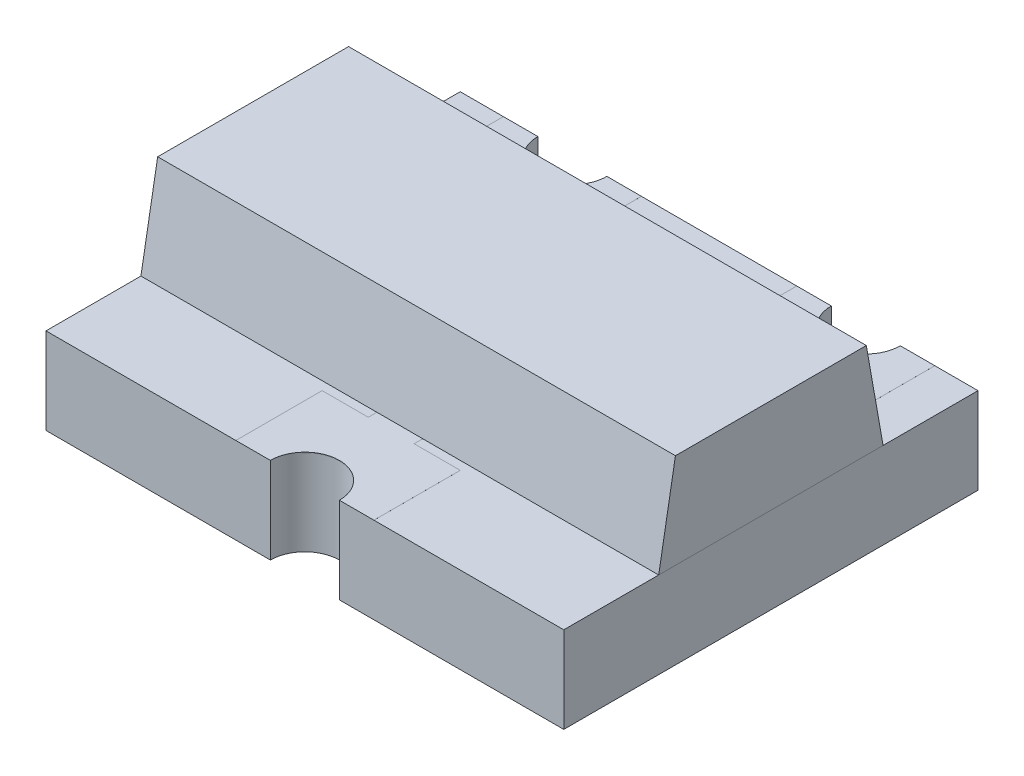
from build123d import *

# Parameters (mm, degrees)
SKETCH1_W             = 2.4
SKETCH1_H             = 0.5
EXTRUDE1_DEPTH        = 1.5
EXTRUDE2_DEPTH        = 1.5
CUT_EXTRUDE1_DEPTH    = 2.05
EXTRUDE3_DEPTH        = 0.0001
EXTRUDE3_DEPTH_BACK   = 0.003
EXTRUDE3_2_DEPTH      = 0.0001
EXTRUDE3_2_DEPTH_BACK = 0.003
EXTRUDE3_3_DEPTH      = 0.0001
EXTRUDE3_3_DEPTH_BACK = 0.003
EXTRUDE4_DEPTH        = 0.0001
EXTRUDE4_DEPTH_BACK   = 0.003
EXTRUDE4_2_DEPTH      = 0.0001
EXTRUDE4_2_DEPTH_BACK = 0.003
EXTRUDE4_3_DEPTH      = 0.0001
EXTRUDE4_3_DEPTH_BACK = 0.003
SKETCH4_W             = 0.026582278
SKETCH4_H             = 0.025316455
SKETCH4_H_2           = 0.025316456
CUT_EXTRUDE2_DEPTH    = 0.01


with BuildPart() as part:
    # Sketch1 → Extrude1 (new body, symmetric)
    with BuildSketch(Plane(origin=(0, 0, 0), x_dir=(0, 0, -1), z_dir=(1, 0, 0))):
        Rectangle(SKETCH1_W, SKETCH1_H)
    extrude(amount=EXTRUDE1_DEPTH, both=True)

    # Sketch2 → Cut-Extrude1 (cut, through all)
    with BuildSketch(Plane.XZ.offset(0.25)):
        with BuildLine():
            Line((0.2, 1.2), (-0.2, 1.2))
            ThreePointArc((-0.2, 1.2), (0, 1), (0.2, 1.2))
        make_face()
        with BuildLine():
            ThreePointArc((-0.65, -1.2), (-0.85, -1), (-1.05, -1.2))
            Line((-1.05, -1.2), (-0.65, -1.2))
        make_face()
        with BuildLine():
            ThreePointArc((1.05, -1.2), (0.85, -1), (0.65, -1.2))
            Line((0.65, -1.2), (1.05, -1.2))
        make_face()
    extrude(amount=-CUT_EXTRUDE1_DEPTH, mode=Mode.SUBTRACT)

    # Sketch4 → Cut-Extrude2 (cut)
    with BuildSketch(Plane.XZ.offset(0.25)):
        Polygon((1.357409322, -0.579474052), (1.432092866, -0.602931331), (1.432092866, -0.62767421), (1.381756632, -0.64409035), (1.432092866, -0.659616457), (1.432092866, -0.685348261), (1.357409322, -0.708587976), (1.357409322, -0.68340997), (1.408892708, -0.670415508), (1.357409322, -0.653999369), (1.357409322, -0.63250016), (1.408892708, -0.616182913), (1.357409322, -0.603366457), align=None)
        Polygon((1.357409322, -0.445296837), (1.432092866, -0.468754116), (1.432092866, -0.493496995), (1.381756632, -0.509913135), (1.432092866, -0.525439242), (1.432092866, -0.551171046), (1.357409322, -0.574410761), (1.357409322, -0.549232755), (1.408892708, -0.536238293), (1.357409322, -0.519822154), (1.357409322, -0.498322945), (1.408892708, -0.482005698), (1.357409322, -0.469189242), align=None)
        Polygon((1.357409322, -0.311119622), (1.432092866, -0.3345769), (1.432092866, -0.35931978), (1.381756632, -0.375735919), (1.432092866, -0.391262027), (1.432092866, -0.416993831), (1.357409322, -0.440233546), (1.357409322, -0.41505554), (1.408892708, -0.402061078), (1.357409322, -0.385644938), (1.357409322, -0.364145729), (1.408892708, -0.347828483), (1.357409322, -0.335012027), align=None)
        with Locations((1.418801727, -0.283271521)):
            Rectangle(SKETCH4_W, SKETCH4_H)
        with BuildLine():
            add(Edge.make_bspline(
                [(1.40092198, -0.166815824), (1.402144102, -0.166852343), (1.404543941, -0.166924054), (1.408051798, -0.167533348), (1.411375482, -0.16852839), (1.41453672, -0.169894506), (1.417501146, -0.171703871), (1.420297161, -0.173885176), (1.422911359, -0.176472683), (1.425319887, -0.179429064), (1.42752455, -0.182710159), (1.429415656, -0.18631264), (1.431042191, -0.190181635), (1.432373366, -0.194336031), (1.433364281, -0.198781501), (1.434087556, -0.203499309), (1.434561076, -0.208492649), (1.434603015, -0.211916238), (1.434624512, -0.213671046)],
                knots=[0, 0, 0, 0, 0.907462679, 1.781953809, 2.635804048, 3.480274448, 4.332887508, 5.208817748, 6.109340518, 7.059474472, 8.037577805, 9.041105121, 10.077237313, 11.152245627, 12.27748741, 13.457227022, 14.696666784, 16, 16, 16, 16], degree=3))
            add(Edge.make_bspline(
                [(1.434624512, -0.213671046), (1.434597247, -0.21568903), (1.434544443, -0.219597217), (1.43415907, -0.225264785), (1.433471121, -0.230528251), (1.43251454, -0.235425998), (1.431311255, -0.240030299), (1.430020611, -0.244463643), (1.428556031, -0.248744936), (1.427455894, -0.251518028), (1.426910904, -0.252891774)],
                knots=[0, 0, 0, 0, 1.203182053, 2.33017619, 3.384818652, 4.366208123, 5.30340534, 6.221361684, 7.118890722, 8, 8, 8, 8], degree=3))
            Line((1.426910904, -0.252891774), (1.402978942, -0.252891774))
            Line((1.402978942, -0.252891774), (1.402978942, -0.250043673))
            add(Edge.make_bspline(
                [(1.402978942, -0.250043673), (1.404059905, -0.248678109), (1.406215484, -0.245955), (1.408983838, -0.241528042), (1.411356849, -0.23686903), (1.413339471, -0.232030636), (1.414915085, -0.227129267), (1.416041991, -0.2222602), (1.416781355, -0.217491217), (1.416862917, -0.214332895), (1.416902993, -0.212781014)],
                knots=[0, 0, 0, 0, 1.030738938, 2.055426519, 3.085610749, 4.123842265, 5.148648843, 6.130724483, 7.081507926, 8, 8, 8, 8], degree=3))
            add(Edge.make_bspline(
                [(1.416902993, -0.212781014), (1.416901657, -0.212352271), (1.416898796, -0.211434366), (1.416778683, -0.209971709), (1.416648283, -0.208322187), (1.416454285, -0.206547796), (1.416219913, -0.204754627), (1.415878731, -0.203086728), (1.415506623, -0.201579962), (1.415139525, -0.200673259), (1.414964702, -0.200241457)],
                knots=[0, 0, 0, 0, 0.806557331, 1.726776592, 2.760222249, 3.920734434, 5.085813889, 6.161303184, 7.124353598, 8, 8, 8, 8], degree=3))
            add(Edge.make_bspline(
                [(1.414964702, -0.200241457), (1.414736149, -0.1997622), (1.414286993, -0.198820358), (1.41348033, -0.197519041), (1.412573518, -0.196363719), (1.41161213, -0.195306974), (1.410461484, -0.194420649), (1.40905428, -0.193803788), (1.407406295, -0.193457421), (1.406230936, -0.193418619), (1.40560948, -0.193398103)],
                knots=[0, 0, 0, 0, 1.025060442, 2.01446193, 2.949256246, 3.85908539, 4.768290539, 5.73153362, 6.800575992, 8, 8, 8, 8], degree=3))
            add(Edge.make_bspline(
                [(1.40560948, -0.193398103), (1.405063873, -0.193429967), (1.403991047, -0.193492622), (1.402455498, -0.194069528), (1.401048086, -0.194980127), (1.399774675, -0.196254099), (1.398656404, -0.19786689), (1.397633759, -0.199784472), (1.396804846, -0.202055523), (1.396366253, -0.203692335), (1.396135588, -0.204553166)],
                knots=[0, 0, 0, 0, 0.825786558, 1.623739628, 2.456775365, 3.355767579, 4.339087636, 5.42728423, 6.646958453, 8, 8, 8, 8], degree=3))
            add(Edge.make_bspline(
                [(1.396135588, -0.204553166), (1.395689878, -0.206522304), (1.394775139, -0.210563612), (1.393596045, -0.216705147), (1.392361392, -0.222841983), (1.391149974, -0.226792288), (1.390558056, -0.22872247)],
                knots=[0, 0, 0, 0, 0.976116373, 2.003306214, 3.02438349, 4, 4, 4, 4], degree=3))
            add(Edge.make_bspline(
                [(1.390558056, -0.22872247), (1.390204336, -0.229760625), (1.389515786, -0.231781492), (1.388363103, -0.234680651), (1.387058091, -0.237324013), (1.385735631, -0.239781157), (1.38425703, -0.241975186), (1.382716285, -0.243968899), (1.381077327, -0.245741204), (1.379319943, -0.247266714), (1.377484875, -0.248611161), (1.375536659, -0.249762187), (1.373475343, -0.250730304), (1.371310886, -0.251522736), (1.369041626, -0.252141567), (1.366664356, -0.252561712), (1.364181105, -0.252860408), (1.362486737, -0.252881176), (1.361622138, -0.252891774)],
                knots=[0, 0, 0, 0, 1.287139616, 2.505537848, 3.65787682, 4.745319116, 5.777517297, 6.75878323, 7.700384896, 8.605120322, 9.485712598, 10.366814604, 11.256335458, 12.154696155, 13.068779358, 14.012730507, 14.985940713, 16, 16, 16, 16], degree=3))
            add(Edge.make_bspline(
                [(1.361622138, -0.252891774), (1.360465992, -0.252854473), (1.358190717, -0.252781067), (1.354861695, -0.252179617), (1.351712876, -0.251153106), (1.34870972, -0.249766747), (1.345895457, -0.247939254), (1.34321797, -0.245747131), (1.340725474, -0.243136821), (1.338426838, -0.240151494), (1.336348032, -0.236864646), (1.334511324, -0.233330641), (1.333004877, -0.22955179), (1.331723646, -0.225571905), (1.330771251, -0.221352512), (1.330051673, -0.216915542), (1.329638672, -0.212241679), (1.329587397, -0.209050268), (1.329561221, -0.207421046)],
                knots=[0, 0, 0, 0, 0.894901293, 1.761149761, 2.608783409, 3.453876344, 4.314933854, 5.200038827, 6.12799933, 7.103249695, 8.113098521, 9.136064399, 10.182719798, 11.259667356, 12.370545059, 13.528828137, 14.738461593, 16, 16, 16, 16], degree=3))
            add(Edge.make_bspline(
                [(1.329561221, -0.207421046), (1.329583575, -0.205752388), (1.329628246, -0.2024179), (1.330003788, -0.197436028), (1.330567386, -0.192484697), (1.331374369, -0.187614536), (1.332383832, -0.182930403), (1.33347328, -0.178507926), (1.334713205, -0.17442886), (1.335667308, -0.171855147), (1.336127676, -0.170613293)],
                knots=[0, 0, 0, 0, 1.065384654, 2.128962885, 3.18847586, 4.246683315, 5.279600907, 6.247539799, 7.154412252, 8, 8, 8, 8], degree=3))
            Line((1.336127676, -0.170613293), (1.358675145, -0.170613293))
            Line((1.358675145, -0.170613293), (1.358675145, -0.173441616))
            add(Edge.make_bspline(
                [(1.358675145, -0.173441616), (1.357876, -0.174515174), (1.356245126, -0.176706063), (1.354141092, -0.180354786), (1.352209389, -0.184328245), (1.35048006, -0.188595928), (1.349060928, -0.193069219), (1.348031492, -0.197646565), (1.347392471, -0.202273682), (1.347319325, -0.205375266), (1.34728274, -0.206926584)],
                knots=[0, 0, 0, 0, 0.892231706, 1.82084296, 2.804411717, 3.838445872, 4.890103822, 5.931567007, 6.965432763, 8, 8, 8, 8], degree=3))
            add(Edge.make_bspline(
                [(1.34728274, -0.206926584), (1.347307388, -0.208021822), (1.347356814, -0.210218), (1.347700294, -0.2134934), (1.348379997, -0.216726573), (1.349191103, -0.218763645), (1.349596822, -0.219782597)],
                knots=[0, 0, 0, 0, 0.99896713, 2.003134239, 3.001159596, 4, 4, 4, 4], degree=3))
            add(Edge.make_bspline(
                [(1.349596822, -0.219782597), (1.349798017, -0.220216302), (1.350200272, -0.221083424), (1.350979663, -0.222291326), (1.351896903, -0.223410919), (1.352950168, -0.224415465), (1.354131235, -0.225239604), (1.355393906, -0.225880883), (1.356756839, -0.226240311), (1.357690879, -0.226286335), (1.358160904, -0.226309495)],
                knots=[0, 0, 0, 0, 1.005120364, 2.009570296, 3.014977851, 4.045438181, 5.061509448, 6.035608779, 7.011484765, 8, 8, 8, 8], degree=3))
            add(Edge.make_bspline(
                [(1.358160904, -0.226309495), (1.358798835, -0.226274701), (1.360017863, -0.226208212), (1.361731559, -0.225608215), (1.363194671, -0.224610546), (1.364187665, -0.223457447), (1.364886424, -0.222340468), (1.365391664, -0.22129995), (1.365905087, -0.220100499), (1.366394284, -0.218723051), (1.36688833, -0.217187916), (1.367363, -0.215478993), (1.36781256, -0.213596386), (1.368098712, -0.212280495), (1.36824793, -0.211594305)],
                knots=[0, 0, 0, 0, 1.174343879, 2.244064321, 3.303704314, 4.407076671, 5.02483983, 5.732197225, 6.53898402, 7.431906431, 8.428480183, 9.514816237, 10.704066255, 12, 12, 12, 12], degree=3))
            add(Edge.make_bspline(
                [(1.36824793, -0.211594305), (1.36862403, -0.209761546), (1.369361688, -0.206166901), (1.370464919, -0.200763811), (1.371767782, -0.19526851), (1.372900174, -0.19159214), (1.373489227, -0.189679748)],
                knots=[0, 0, 0, 0, 0.995794372, 1.953081347, 2.935223864, 4, 4, 4, 4], degree=3))
            add(Edge.make_bspline(
                [(1.373489227, -0.189679748), (1.373808583, -0.188733258), (1.374433296, -0.186881769), (1.375518016, -0.184240255), (1.37669998, -0.181791087), (1.377922905, -0.179513216), (1.379284597, -0.177449747), (1.380701928, -0.175564911), (1.382207902, -0.173867749), (1.383823255, -0.172378618), (1.385533932, -0.171050616), (1.387383584, -0.169935611), (1.389332747, -0.168948996), (1.391413181, -0.168157378), (1.393624143, -0.1675729), (1.395951027, -0.167140221), (1.398396179, -0.166849012), (1.400070649, -0.166827011), (1.40092198, -0.166815824)],
                knots=[0, 0, 0, 0, 1.237247399, 2.420255609, 3.534416354, 4.605351393, 5.620193117, 6.593738998, 7.524982051, 8.426564095, 9.311945829, 10.20281032, 11.097671666, 12.01534975, 12.954438892, 13.926750701, 14.945921247, 16, 16, 16, 16], degree=3))
        make_face()
        with BuildLine():
            Line((1.432092866, -0.074410761), (1.432092866, -0.098461394))
            Line((1.432092866, -0.098461394), (1.424260588, -0.098461394))
            add(Edge.make_bspline(
                [(1.424260588, -0.098461394), (1.425069491, -0.099554535), (1.426629045, -0.101662095), (1.428704658, -0.104837359), (1.430496984, -0.107858328), (1.432003008, -0.110796755), (1.433230662, -0.113796159), (1.434042817, -0.117030317), (1.434546898, -0.120531344), (1.434598066, -0.122958496), (1.434624512, -0.124212976)],
                knots=[0, 0, 0, 0, 1.15097647, 2.219065785, 3.209751872, 4.123278731, 5.012494873, 5.946522673, 6.938654008, 8, 8, 8, 8], degree=3))
            add(Edge.make_bspline(
                [(1.434624512, -0.124212976), (1.434601554, -0.125229245), (1.434556848, -0.127208213), (1.434215267, -0.130086602), (1.433666366, -0.132788253), (1.432899684, -0.135318195), (1.431888271, -0.13766922), (1.430637573, -0.139826899), (1.429175705, -0.141813567), (1.427499451, -0.143617219), (1.425578304, -0.145207764), (1.423455604, -0.146594835), (1.421120951, -0.147770642), (1.418569589, -0.148712281), (1.415811143, -0.149467214), (1.412831937, -0.149991192), (1.409644797, -0.150311771), (1.407449669, -0.150343712), (1.406321505, -0.150360128)],
                knots=[0, 0, 0, 0, 1.108887696, 2.159324556, 3.158383213, 4.114277414, 5.039206009, 5.945047284, 6.830075132, 7.726032535, 8.625162295, 9.545152215, 10.487958828, 11.471559655, 12.508379831, 13.604991163, 14.769110247, 16, 16, 16, 16], degree=3))
            Line((1.406321505, -0.150360128), (1.357409322, -0.150360128))
            Line((1.357409322, -0.150360128), (1.357409322, -0.126309495))
            Line((1.357409322, -0.126309495), (1.394988436, -0.126309495))
            add(Edge.make_bspline(
                [(1.394988436, -0.126309495), (1.395904907, -0.12630786), (1.397659122, -0.126304729), (1.400164929, -0.12622239), (1.402433102, -0.12610149), (1.40447513, -0.125962785), (1.406321881, -0.125709768), (1.407988042, -0.12533206), (1.409507644, -0.124861234), (1.410414345, -0.124396915), (1.410850778, -0.124173419)],
                knots=[0, 0, 0, 0, 1.361401701, 2.605856924, 3.723918663, 4.735739235, 5.645738665, 6.489217889, 7.27279937, 8, 8, 8, 8], degree=3))
            add(Edge.make_bspline(
                [(1.410850778, -0.124173419), (1.411249416, -0.123943378), (1.412033105, -0.123491136), (1.413040386, -0.12257135), (1.413876778, -0.121495268), (1.414551477, -0.120226026), (1.415026638, -0.118729905), (1.415413818, -0.117004998), (1.415584035, -0.115012606), (1.415618777, -0.113605236), (1.41563717, -0.112860128)],
                knots=[0, 0, 0, 0, 0.848923305, 1.668910138, 2.502822694, 3.358979167, 4.311113223, 5.396624103, 6.621686681, 8, 8, 8, 8], degree=3))
            add(Edge.make_bspline(
                [(1.41563717, -0.112860128), (1.415617222, -0.112319208), (1.415576235, -0.111207836), (1.415387204, -0.109496447), (1.414983045, -0.107714807), (1.414339075, -0.105196454), (1.413152112, -0.102021762), (1.411794586, -0.099657385), (1.411107898, -0.098461394)],
                knots=[0, 0, 0, 0, 0.638098464, 1.31103257, 2.025970928, 2.789492669, 4.376004971, 6, 6, 6, 6], degree=3))
            Line((1.411107898, -0.098461394), (1.357409322, -0.098461394))
            Line((1.357409322, -0.098461394), (1.357409322, -0.074410761))
            Line((1.357409322, -0.074410761), (1.432092866, -0.074410761))
        make_face()
        with BuildLine():
            Line((1.432092866, 0.023057593), (1.432092866, -0.00099304))
            Line((1.432092866, -0.00099304), (1.394513752, -0.00099304))
            add(Edge.make_bspline(
                [(1.394513752, -0.00099304), (1.39298333, -0.00101385), (1.389924446, -0.001055445), (1.386167044, -0.001383651), (1.383319969, -0.001723123), (1.381490218, -0.00209788), (1.3799419, -0.002528222), (1.379056161, -0.002940651), (1.378651411, -0.003129116)],
                knots=[0, 0, 0, 0, 1.709225407, 3.416259723, 4.21101956, 4.910102269, 5.501957085, 6, 6, 6, 6], degree=3))
            add(Edge.make_bspline(
                [(1.378651411, -0.003129116), (1.378253279, -0.003373542), (1.377472685, -0.003852775), (1.3764608, -0.004790617), (1.375624056, -0.005887163), (1.374961207, -0.007166296), (1.374466799, -0.008647883), (1.374120517, -0.010367713), (1.373908294, -0.012347247), (1.373879994, -0.013756174), (1.373865018, -0.014501742)],
                knots=[0, 0, 0, 0, 0.860284341, 1.686708632, 2.528476982, 3.393563585, 4.332150703, 5.400907339, 6.624626855, 8, 8, 8, 8], degree=3))
            add(Edge.make_bspline(
                [(1.373865018, -0.014501742), (1.373924963, -0.015632699), (1.374047287, -0.017940532), (1.37471602, -0.020814945), (1.375569249, -0.023128581), (1.376335164, -0.024979368), (1.377292463, -0.026894983), (1.378019154, -0.028178538), (1.37839429, -0.028841141)],
                knots=[0, 0, 0, 0, 1.338233385, 2.730803257, 3.468495571, 4.255080394, 5.099229486, 6, 6, 6, 6], degree=3))
            Line((1.37839429, -0.028841141), (1.432092866, -0.028841141))
            Line((1.432092866, -0.028841141), (1.432092866, -0.052891774))
            Line((1.432092866, -0.052891774), (1.357409322, -0.052891774))
            Line((1.357409322, -0.052891774), (1.357409322, -0.028841141))
            Line((1.357409322, -0.028841141), (1.3652416, -0.028841141))
            add(Edge.make_bspline(
                [(1.3652416, -0.028841141), (1.364435163, -0.027783903), (1.362865384, -0.025725928), (1.360831974, -0.022549175), (1.359022117, -0.019478464), (1.357509983, -0.016423942), (1.356311383, -0.013299444), (1.35549578, -0.010031813), (1.354952832, -0.006615101), (1.35490302, -0.004278428), (1.354877676, -0.003089559)],
                knots=[0, 0, 0, 0, 1.126064518, 2.191951536, 3.19307265, 4.144813015, 5.076393104, 6.021983703, 6.993610568, 8, 8, 8, 8], degree=3))
            add(Edge.make_bspline(
                [(1.354877676, -0.003089559), (1.354903077, -0.002093294), (1.354952663, -0.000148407), (1.355262215, 0.002686442), (1.355813438, 0.005357549), (1.356609294, 0.007850934), (1.357600654, 0.010186617), (1.358804629, 0.012360301), (1.360267926, 0.014346105), (1.361927805, 0.016174425), (1.363819332, 0.017812888), (1.365947823, 0.019212251), (1.368290311, 0.020408123), (1.370839855, 0.021395442), (1.373618813, 0.022146481), (1.376612194, 0.022662664), (1.379823091, 0.023016942), (1.382039097, 0.023043772), (1.383180683, 0.023057593)],
                knots=[0, 0, 0, 0, 1.088244909, 2.124447647, 3.110254678, 4.062235362, 4.978491991, 5.877983887, 6.769571508, 7.666696544, 8.570415953, 9.495151274, 10.442024977, 11.43832337, 12.476026402, 13.580659577, 14.753665747, 16, 16, 16, 16], degree=3))
            Line((1.383180683, 0.023057593), (1.432092866, 0.023057593))
        make_face()
        Polygon((1.432092866, 0.117994302), (1.432092866, 0.045842403), (1.332092866, 0.045842403), (1.332092866, 0.071158859), (1.413105524, 0.071158859), (1.413105524, 0.117994302), align=None)
        Polygon((1.432092866, 0.205336074), (1.432092866, 0.133184176), (1.332092866, 0.133184176), (1.332092866, 0.205336074), (1.351080208, 0.205336074), (1.351080208, 0.158500631), (1.368801727, 0.158500631), (1.368801727, 0.201538606), (1.387789069, 0.201538606), (1.387789069, 0.158500631), (1.413105524, 0.158500631), (1.413105524, 0.205336074), align=None)
        with BuildLine():
            add(Edge.make_bspline(
                [(1.382191759, 0.321791771), (1.383339447, 0.321772455), (1.385612334, 0.321734203), (1.38897714, 0.321439012), (1.392242816, 0.320912986), (1.395427064, 0.320233805), (1.398505992, 0.319311299), (1.401513569, 0.318229586), (1.404419063, 0.31691994), (1.407220497, 0.315415087), (1.4098926, 0.313765615), (1.412412809, 0.311990866), (1.414796026, 0.310145087), (1.41699092, 0.308155774), (1.41903294, 0.306076592), (1.420923754, 0.303901064), (1.422627185, 0.301595999), (1.423650069, 0.299988837), (1.424161695, 0.299184967)],
                knots=[0, 0, 0, 0, 1.105570398, 2.18947457, 3.250358341, 4.290584537, 5.323553275, 6.344225964, 7.367641686, 8.3905646, 9.405808457, 10.390761353, 11.358902336, 12.307789878, 13.241960776, 14.165076779, 15.082208636, 16, 16, 16, 16], degree=3))
            add(Edge.make_bspline(
                [(1.424161695, 0.299184967), (1.424874046, 0.297945787), (1.426302382, 0.295461104), (1.427967773, 0.291476539), (1.429385809, 0.287349271), (1.43039302, 0.282981956), (1.431164499, 0.278343867), (1.431714982, 0.273345824), (1.432019079, 0.267945377), (1.43206771, 0.264210397), (1.432092866, 0.262278321)],
                knots=[0, 0, 0, 0, 0.896331627, 1.797236794, 2.705411718, 3.632841792, 4.606367508, 5.655603524, 6.787262262, 8, 8, 8, 8], degree=3))
            Line((1.432092866, 0.262278321), (1.432092866, 0.226855062))
            Line((1.432092866, 0.226855062), (1.332092866, 0.226855062))
            Line((1.332092866, 0.226855062), (1.332092866, 0.263287024))
            add(Edge.make_bspline(
                [(1.332092866, 0.263287024), (1.332109761, 0.265265712), (1.332142348, 0.269082356), (1.332555657, 0.274593251), (1.333164078, 0.279688767), (1.334060087, 0.284377578), (1.335167973, 0.288688435), (1.336560442, 0.292611262), (1.338052626, 0.29622761), (1.339327234, 0.298406131), (1.339944923, 0.299461865)],
                knots=[0, 0, 0, 0, 1.267100211, 2.444079055, 3.537724964, 4.552266402, 5.499704501, 6.385138932, 7.217420793, 8, 8, 8, 8], degree=3))
            add(Edge.make_bspline(
                [(1.339944923, 0.299461865), (1.340481464, 0.300312819), (1.341548377, 0.302004943), (1.34333023, 0.304406158), (1.345286307, 0.306635585), (1.347338125, 0.308764089), (1.349541013, 0.310743903), (1.351879717, 0.312587116), (1.354357824, 0.314290882), (1.356967243, 0.315849038), (1.359697483, 0.317269123), (1.362569828, 0.318461203), (1.365552702, 0.319500565), (1.368651641, 0.320346647), (1.371869031, 0.321002977), (1.375206511, 0.321449061), (1.378659699, 0.321732494), (1.381004493, 0.321771845), (1.382191759, 0.321791771)],
                knots=[0, 0, 0, 0, 0.964043478, 1.917004671, 2.862223898, 3.805158963, 4.749279098, 5.698713747, 6.657523689, 7.629652222, 8.610369353, 9.604453025, 10.607693792, 11.636365947, 12.681120053, 13.752669011, 14.862083412, 16, 16, 16, 16], degree=3))
        make_face()
        with BuildLine():
            add(Edge.make_bspline(
                [(1.382033531, 0.295209492), (1.380455675, 0.29516309), (1.377410007, 0.295073522), (1.373005805, 0.294409979), (1.36897254, 0.293230448), (1.365856036, 0.291901212), (1.363583021, 0.290562667), (1.36198469, 0.289435373), (1.360470507, 0.288185646), (1.359061662, 0.286795053), (1.357754627, 0.285259865), (1.356525717, 0.283598607), (1.355397071, 0.281798565), (1.354737065, 0.280525534), (1.354402993, 0.279881169)],
                knots=[0, 0, 0, 0, 1.694561208, 3.270940604, 4.767926833, 6.198032689, 6.896357436, 7.597727349, 8.296769799, 9.00280713, 9.720956486, 10.460265288, 11.220639329, 12, 12, 12, 12], degree=3))
            add(Edge.make_bspline(
                [(1.354402993, 0.279881169), (1.354096478, 0.279206234), (1.353488946, 0.277868466), (1.352754859, 0.27579819), (1.352192532, 0.273705489), (1.351720109, 0.271511262), (1.351442973, 0.269034502), (1.351230297, 0.26611201), (1.351093369, 0.262655337), (1.351084799, 0.260168742), (1.351080208, 0.258836865)],
                knots=[0, 0, 0, 0, 0.826913061, 1.638999358, 2.447478739, 3.243919028, 4.140906711, 5.225381046, 6.513851968, 8, 8, 8, 8], degree=3))
            Line((1.351080208, 0.258836865), (1.351080208, 0.252171517))
            Line((1.351080208, 0.252171517), (1.413105524, 0.252171517))
            Line((1.413105524, 0.252171517), (1.413105524, 0.258836865))
            add(Edge.make_bspline(
                [(1.413105524, 0.258836865), (1.413100482, 0.259595057), (1.413090749, 0.261058793), (1.413051596, 0.263175241), (1.412991447, 0.265140022), (1.412919049, 0.266947308), (1.412806399, 0.268597111), (1.412632409, 0.270084304), (1.412495711, 0.271421114), (1.412218588, 0.272993632), (1.41181234, 0.274848802), (1.411129269, 0.277015597), (1.410279671, 0.279156294), (1.409594596, 0.280544845), (1.409248721, 0.281245884)],
                knots=[0, 0, 0, 0, 1.186788252, 2.291168447, 3.31326867, 4.263560303, 5.122314491, 5.900668105, 6.60723418, 7.224768558, 8.398927205, 9.577205322, 10.776800932, 12, 12, 12, 12], degree=3))
            add(Edge.make_bspline(
                [(1.409248721, 0.281245884), (1.408905243, 0.281829596), (1.408229756, 0.282977528), (1.407123916, 0.284621707), (1.405888832, 0.286108319), (1.404606041, 0.287514846), (1.403214462, 0.288766006), (1.401770921, 0.289943305), (1.400196379, 0.290928546), (1.398007444, 0.292177416), (1.394980287, 0.293420992), (1.391008363, 0.294454607), (1.386649209, 0.295093399), (1.383611503, 0.295169803), (1.382033531, 0.295209492)],
                knots=[0, 0, 0, 0, 0.755184287, 1.485151634, 2.206180267, 2.908413556, 3.605665444, 4.291074465, 4.982332562, 5.673512475, 7.100235687, 8.614142391, 10.24117603, 12, 12, 12, 12], degree=3))
        make_face(mode=Mode.SUBTRACT)
        with Locations((1.418801727, 0.35343734)):
            Rectangle(SKETCH4_W, SKETCH4_H_2)
        with BuildLine():
            add(Edge.make_bspline(
                [(1.434624512, 0.428081327), (1.434602693, 0.426491218), (1.434559867, 0.423370089), (1.434083055, 0.418798697), (1.433364984, 0.414433703), (1.432345407, 0.410286763), (1.430996034, 0.406383478), (1.429360961, 0.402711095), (1.427361123, 0.399311887), (1.425778506, 0.397244904), (1.424992392, 0.396218195)],
                knots=[0, 0, 0, 0, 1.123640227, 2.2055255, 3.245221982, 4.248949655, 5.220213072, 6.160941522, 7.086505793, 8, 8, 8, 8], degree=3))
            add(Edge.make_bspline(
                [(1.424992392, 0.396218195), (1.424137559, 0.39526656), (1.422431198, 0.39336697), (1.419460655, 0.390899343), (1.416171682, 0.388781267), (1.412580029, 0.386969012), (1.408660143, 0.38553706), (1.404410249, 0.384544525), (1.399852919, 0.383916921), (1.396704715, 0.38385097), (1.395087328, 0.383817087)],
                knots=[0, 0, 0, 0, 0.916342154, 1.829140869, 2.758848968, 3.716597128, 4.708179637, 5.743612459, 6.840783343, 8, 8, 8, 8], degree=3))
            add(Edge.make_bspline(
                [(1.395087328, 0.383817087), (1.393384101, 0.383855847), (1.390083021, 0.38393097), (1.385310834, 0.38459473), (1.380893153, 0.385664342), (1.376841245, 0.3872019), (1.373148053, 0.389132342), (1.369776218, 0.391396835), (1.366733294, 0.394017361), (1.364987855, 0.396024499), (1.364114227, 0.397029112)],
                knots=[0, 0, 0, 0, 1.171797512, 2.271099083, 3.308930235, 4.294129479, 5.24602549, 6.17106565, 7.084581485, 8, 8, 8, 8], degree=3))
            add(Edge.make_bspline(
                [(1.364114227, 0.397029112), (1.363345573, 0.39805494), (1.361798981, 0.400118984), (1.359902261, 0.403517865), (1.358304295, 0.407134537), (1.357029335, 0.41095782), (1.35608009, 0.414940522), (1.355384324, 0.419009962), (1.354956181, 0.423153879), (1.354903971, 0.425944244), (1.354877676, 0.427349524)],
                knots=[0, 0, 0, 0, 0.952013349, 1.915525331, 2.885385798, 3.888123097, 4.906830296, 5.926067872, 6.955529031, 8, 8, 8, 8], degree=3))
            add(Edge.make_bspline(
                [(1.354877676, 0.427349524), (1.354894035, 0.428596336), (1.354926201, 0.431047992), (1.355257359, 0.434646718), (1.355756376, 0.438098715), (1.356499947, 0.441398006), (1.357422761, 0.444564203), (1.358446909, 0.447627653), (1.359586819, 0.45059189), (1.360470776, 0.452492644), (1.360910113, 0.45343734)],
                knots=[0, 0, 0, 0, 1.107572103, 2.177862056, 3.208491727, 4.204802822, 5.180069889, 6.137814326, 7.074472616, 8, 8, 8, 8], degree=3))
            Line((1.360910113, 0.45343734), (1.381459955, 0.45343734))
            Line((1.381459955, 0.45343734), (1.381459955, 0.450094777))
            add(Edge.make_bspline(
                [(1.381459955, 0.450094777), (1.381043063, 0.449594981), (1.380136126, 0.448507689), (1.378709241, 0.446725865), (1.377187976, 0.444570953), (1.376299309, 0.442926284), (1.375823088, 0.442044935)],
                knots=[0, 0, 0, 0, 0.792806788, 1.724728901, 2.780722718, 4, 4, 4, 4], degree=3))
            add(Edge.make_bspline(
                [(1.375823088, 0.442044935), (1.375383543, 0.441116276), (1.374479051, 0.43920529), (1.373614767, 0.436658171), (1.373078785, 0.434457847), (1.372816761, 0.432649897), (1.372629146, 0.430715787), (1.372609362, 0.429380614), (1.372599195, 0.42869446)],
                knots=[0, 0, 0, 0, 1.332411269, 2.741822805, 3.48048496, 4.268099981, 5.109965479, 6, 6, 6, 6], degree=3))
            add(Edge.make_bspline(
                [(1.372599195, 0.42869446), (1.372618536, 0.427928828), (1.372656017, 0.426445069), (1.37293593, 0.424284607), (1.373404503, 0.422260327), (1.374080746, 0.420371096), (1.374941051, 0.418616536), (1.375961211, 0.416980866), (1.377213201, 0.415505224), (1.378631633, 0.414163598), (1.380221957, 0.412976026), (1.381948496, 0.411949297), (1.383806375, 0.411066564), (1.385804287, 0.410364673), (1.387934148, 0.409807162), (1.390196958, 0.409417597), (1.392596556, 0.409175818), (1.394242852, 0.409147876), (1.395087328, 0.409133543)],
                knots=[0, 0, 0, 0, 1.087164589, 2.106874378, 3.088024391, 4.032801718, 4.949890679, 5.859058447, 6.763003849, 7.690312844, 8.626654282, 9.575690722, 10.539030902, 11.54301425, 12.578634972, 13.662366762, 14.800897888, 16, 16, 16, 16], degree=3))
            add(Edge.make_bspline(
                [(1.395087328, 0.409133543), (1.395951485, 0.409148317), (1.397630497, 0.409177023), (1.400072108, 0.409410537), (1.402353539, 0.409826428), (1.404478859, 0.410397676), (1.406444878, 0.411122024), (1.408242274, 0.412027142), (1.409899081, 0.413063498), (1.411361693, 0.414308056), (1.412678015, 0.41567194), (1.413814149, 0.417186831), (1.414762294, 0.418846071), (1.415566757, 0.420628251), (1.416145156, 0.422561292), (1.416581847, 0.424617828), (1.416870404, 0.426807384), (1.416891967, 0.428317737), (1.416902993, 0.42909003)],
                knots=[0, 0, 0, 0, 1.230336593, 2.390482092, 3.487897344, 4.52859895, 5.520747884, 6.465347575, 7.38981449, 8.296085817, 9.192433006, 10.084246191, 10.984321635, 11.908883871, 12.862027947, 13.850751296, 14.901019963, 16, 16, 16, 16], degree=3))
            add(Edge.make_bspline(
                [(1.416902993, 0.42909003), (1.416894138, 0.42981578), (1.416876876, 0.431230603), (1.416669433, 0.433291325), (1.416359044, 0.435241751), (1.415917412, 0.437074021), (1.415412213, 0.438785608), (1.414835016, 0.44034724), (1.414232371, 0.441760362), (1.413764557, 0.442621635), (1.413540651, 0.443033859)],
                knots=[0, 0, 0, 0, 1.201100869, 2.341500598, 3.425337164, 4.468451875, 5.459559168, 6.378110228, 7.223726512, 8, 8, 8, 8], degree=3))
            add(Edge.make_bspline(
                [(1.413540651, 0.443033859), (1.413112965, 0.443742215), (1.412291006, 0.445103589), (1.410870546, 0.446928707), (1.409464106, 0.448572832), (1.408507338, 0.449596938), (1.408042233, 0.450094777)],
                knots=[0, 0, 0, 0, 1.105932972, 2.12546697, 3.088749538, 4, 4, 4, 4], degree=3))
            Line((1.408042233, 0.450094777), (1.408042233, 0.45343734))
            Line((1.408042233, 0.45343734), (1.428750303, 0.45343734))
            add(Edge.make_bspline(
                [(1.428750303, 0.45343734), (1.429187845, 0.452491963), (1.430063035, 0.450600983), (1.431216185, 0.447686205), (1.432189065, 0.444692963), (1.433081411, 0.441641733), (1.433779606, 0.438472101), (1.434268836, 0.435154752), (1.434570575, 0.431673447), (1.434606288, 0.429295031), (1.434624512, 0.428081327)],
                knots=[0, 0, 0, 0, 0.952024047, 1.90427691, 2.862762905, 3.827874523, 4.80891974, 5.826446878, 6.890837857, 8, 8, 8, 8], degree=3))
        make_face()
        with BuildLine():
            add(Edge.make_bspline(
                [(1.394790651, 0.545842403), (1.396295483, 0.545817484), (1.399228804, 0.545768908), (1.403501624, 0.5452327), (1.407532065, 0.544409237), (1.411332903, 0.543275913), (1.414875949, 0.541758059), (1.418171903, 0.539915645), (1.421224085, 0.537742054), (1.424014312, 0.535251736), (1.426512504, 0.53245025), (1.428708697, 0.529376485), (1.430515745, 0.526006618), (1.432042294, 0.522397872), (1.433198396, 0.518508565), (1.434016346, 0.514349471), (1.434550678, 0.509931961), (1.43459949, 0.506893596), (1.434624512, 0.505336074)],
                knots=[0, 0, 0, 0, 1.120122129, 2.18341868, 3.201215738, 4.181270334, 5.131540819, 6.065757527, 6.988093576, 7.916512302, 8.844931028, 9.778115023, 10.722851943, 11.686686084, 12.691660064, 13.738321946, 14.84062285, 16, 16, 16, 16], degree=3))
            add(Edge.make_bspline(
                [(1.434624512, 0.505336074), (1.434599572, 0.503778526), (1.43455092, 0.500740108), (1.43401545, 0.496322973), (1.433202733, 0.492168754), (1.432033497, 0.488284102), (1.430521407, 0.484669791), (1.428707965, 0.481295964), (1.426512712, 0.478221782), (1.424014202, 0.47542058), (1.421224317, 0.472929543), (1.418171087, 0.470758538), (1.414881295, 0.468907599), (1.41132402, 0.467427207), (1.407536812, 0.466254675), (1.403500814, 0.465441896), (1.399229023, 0.464902579), (1.396295557, 0.464854441), (1.394790651, 0.464829745)],
                knots=[0, 0, 0, 0, 1.159424321, 2.261770074, 3.308474541, 4.308788811, 5.277191138, 6.221966496, 7.15518846, 8.08364496, 9.01210146, 9.934475036, 10.868729753, 11.817121636, 12.798654016, 13.816492484, 14.879832297, 16, 16, 16, 16], degree=3))
            add(Edge.make_bspline(
                [(1.394790651, 0.464829745), (1.393279218, 0.464854847), (1.39032619, 0.46490389), (1.386027443, 0.465439557), (1.381966347, 0.46625652), (1.378153796, 0.467422051), (1.37459132, 0.468928329), (1.371285131, 0.470775275), (1.368238358, 0.472971029), (1.365448193, 0.475480464), (1.362953665, 0.47829323), (1.36077556, 0.481380728), (1.358966767, 0.484744268), (1.357439002, 0.488344621), (1.356306456, 0.492232282), (1.3554883, 0.496368909), (1.354950391, 0.500766392), (1.354902356, 0.503785117), (1.354877676, 0.505336074)],
                knots=[0, 0, 0, 0, 1.123883205, 2.195836198, 3.217400301, 4.202580581, 5.156396106, 6.089661422, 7.013912723, 7.944661364, 8.875797629, 9.805201257, 10.748976071, 11.711828658, 12.709674189, 13.755270167, 14.846705509, 16, 16, 16, 16], degree=3))
            add(Edge.make_bspline(
                [(1.354877676, 0.505336074), (1.354902388, 0.506906818), (1.354950502, 0.509964994), (1.355486841, 0.514408323), (1.356299367, 0.518582453), (1.357467437, 0.522480062), (1.358970706, 0.52610407), (1.360825653, 0.529451247), (1.363000003, 0.532536205), (1.365529832, 0.535304468), (1.368324786, 0.537788226), (1.371382466, 0.539950583), (1.374690041, 0.541786059), (1.378251917, 0.543261802), (1.382044549, 0.544436004), (1.386078975, 0.545256416), (1.390353882, 0.545762568), (1.393286025, 0.545815329), (1.394790651, 0.545842403)],
                knots=[0, 0, 0, 0, 1.167473013, 2.273023816, 3.322954552, 4.326451713, 5.293391623, 6.234801871, 7.166614545, 8.093305908, 9.017100806, 9.942078766, 10.872536262, 11.824015763, 12.804065898, 13.820367293, 14.881523901, 16, 16, 16, 16], degree=3))
        make_face()
        with BuildLine():
            add(Edge.make_bspline(
                [(1.413283531, 0.516135125), (1.412783267, 0.516489701), (1.41176517, 0.517211304), (1.410065673, 0.518092759), (1.408223886, 0.518843069), (1.406199127, 0.519463906), (1.403908782, 0.519978707), (1.40125783, 0.520277297), (1.39822308, 0.520510848), (1.396070251, 0.520520717), (1.3949291, 0.520525948)],
                knots=[0, 0, 0, 0, 0.765135464, 1.557141201, 2.384449913, 3.246599353, 4.1996426, 5.311961702, 6.575150963, 8, 8, 8, 8], degree=3))
            add(Edge.make_bspline(
                [(1.3949291, 0.520525948), (1.393854226, 0.520508214), (1.391794885, 0.520474238), (1.388835021, 0.520288454), (1.386145523, 0.519936994), (1.383720815, 0.519443477), (1.381548744, 0.518835888), (1.379616416, 0.518101086), (1.377902461, 0.517267648), (1.37689734, 0.516581893), (1.376416442, 0.516253796)],
                knots=[0, 0, 0, 0, 1.337015307, 2.56157572, 3.686511827, 4.707709802, 5.636963675, 6.488272502, 7.276717686, 8, 8, 8, 8], degree=3))
            add(Edge.make_bspline(
                [(1.376416442, 0.516253796), (1.375978797, 0.515915133), (1.375124055, 0.515253708), (1.374017734, 0.514097207), (1.373147927, 0.512809706), (1.372443194, 0.511444764), (1.371967098, 0.509989081), (1.371601512, 0.508488884), (1.371383088, 0.506931286), (1.371350036, 0.505870749), (1.371333373, 0.505336074)],
                knots=[0, 0, 0, 0, 1.058303018, 2.066917725, 3.046948061, 4.023234392, 4.996907708, 5.970172105, 6.976653347, 8, 8, 8, 8], degree=3))
            add(Edge.make_bspline(
                [(1.371333373, 0.505336074), (1.371344402, 0.504808172), (1.371365977, 0.503775612), (1.371544493, 0.502272535), (1.371844492, 0.500856882), (1.372248678, 0.499511717), (1.372860054, 0.498226569), (1.373708872, 0.496995292), (1.374785451, 0.495779905), (1.375635786, 0.495041577), (1.376080208, 0.494655695)],
                knots=[0, 0, 0, 0, 1.04189444, 2.037910168, 2.982338511, 3.896140384, 4.804271323, 5.778885192, 6.839150358, 8, 8, 8, 8], degree=3))
            add(Edge.make_bspline(
                [(1.376080208, 0.494655695), (1.376553875, 0.494320261), (1.377547983, 0.493616271), (1.379268353, 0.492767082), (1.381213844, 0.491997783), (1.38340498, 0.491318494), (1.38587252, 0.490787309), (1.388631133, 0.490429121), (1.391681068, 0.490184441), (1.393814374, 0.490159325), (1.3949291, 0.490146201)],
                knots=[0, 0, 0, 0, 0.70629823, 1.482341141, 2.329662943, 3.254583898, 4.274063958, 5.401087491, 6.641978366, 8, 8, 8, 8], degree=3))
            add(Edge.make_bspline(
                [(1.3949291, 0.490146201), (1.395931835, 0.490152151), (1.39787396, 0.490163675), (1.400676344, 0.49040574), (1.40328461, 0.490693009), (1.405673261, 0.491178096), (1.407862425, 0.491756439), (1.409820565, 0.492489102), (1.4115683, 0.493328455), (1.412591979, 0.494023679), (1.413085746, 0.494359017)],
                knots=[0, 0, 0, 0, 1.270931856, 2.461574991, 3.564842381, 4.596079713, 5.549239655, 6.432768418, 7.244053423, 8, 8, 8, 8], degree=3))
            add(Edge.make_bspline(
                [(1.413085746, 0.494359017), (1.41350265, 0.494699309), (1.414324604, 0.495370215), (1.415398888, 0.496519025), (1.416278507, 0.497780767), (1.416975212, 0.499141225), (1.417508129, 0.500604667), (1.417908546, 0.502159629), (1.41811961, 0.503820539), (1.418152138, 0.504953161), (1.418168816, 0.505533859)],
                knots=[0, 0, 0, 0, 1.011235752, 1.993715204, 2.946409587, 3.894575777, 4.859533504, 5.869856863, 6.907869553, 8, 8, 8, 8], degree=3))
            add(Edge.make_bspline(
                [(1.418168816, 0.505533859), (1.418118262, 0.506541963), (1.418017937, 0.508542584), (1.417276271, 0.510953887), (1.41641853, 0.512750065), (1.415583865, 0.51401734), (1.41451927, 0.515148566), (1.413700749, 0.515802037), (1.413283531, 0.516135125)],
                knots=[0, 0, 0, 0, 1.494110474, 2.96511767, 3.704956058, 4.446088323, 5.207938169, 6, 6, 6, 6], degree=3))
        make_face(mode=Mode.SUBTRACT)
        with BuildLine():
            Line((1.37839429, 0.636981644), (1.432092866, 0.636981644))
            Line((1.432092866, 0.636981644), (1.432092866, 0.612931011))
            Line((1.432092866, 0.612931011), (1.394236854, 0.612931011))
            add(Edge.make_bspline(
                [(1.394236854, 0.612931011), (1.393346854, 0.612924745), (1.391639289, 0.612912722), (1.389178959, 0.612890209), (1.386931617, 0.612774838), (1.384884282, 0.612678285), (1.383027896, 0.612479601), (1.381348187, 0.61220193), (1.379845191, 0.611773075), (1.378944077, 0.611365649), (1.378512961, 0.611170726)],
                knots=[0, 0, 0, 0, 1.33997484, 2.570892857, 3.703483919, 4.727540125, 5.655929516, 6.512630168, 7.288405602, 8, 8, 8, 8], degree=3))
            add(Edge.make_bspline(
                [(1.378512961, 0.611170726), (1.378127751, 0.610960719), (1.377364169, 0.610544433), (1.376394019, 0.609677577), (1.375589984, 0.60866226), (1.374914413, 0.607498584), (1.374454367, 0.606103565), (1.374093221, 0.604495566), (1.373916737, 0.602630134), (1.373882907, 0.601308085), (1.373865018, 0.600609017)],
                knots=[0, 0, 0, 0, 0.859137151, 1.703023591, 2.531884144, 3.395689496, 4.329139829, 5.403231912, 6.626892925, 8, 8, 8, 8], degree=3))
            add(Edge.make_bspline(
                [(1.373865018, 0.600609017), (1.373887885, 0.600021538), (1.373933824, 0.59884128), (1.374186554, 0.597081009), (1.374650338, 0.595346791), (1.375495619, 0.593127965), (1.376740729, 0.590536779), (1.377856558, 0.588564851), (1.37839429, 0.587614555)],
                knots=[0, 0, 0, 0, 0.759205818, 1.525260036, 2.291692926, 3.073215079, 4.589547174, 6, 6, 6, 6], degree=3))
            Line((1.37839429, 0.587614555), (1.432092866, 0.587614555))
            Line((1.432092866, 0.587614555), (1.432092866, 0.563563922))
            Line((1.432092866, 0.563563922), (1.357409322, 0.563563922))
            Line((1.357409322, 0.563563922), (1.357409322, 0.587614555))
            Line((1.357409322, 0.587614555), (1.3652416, 0.587614555))
            add(Edge.make_bspline(
                [(1.3652416, 0.587614555), (1.364459739, 0.588635345), (1.362941682, 0.590617305), (1.360899026, 0.593637477), (1.359118962, 0.596579172), (1.357568518, 0.599472962), (1.356357804, 0.602435437), (1.355508144, 0.60552849), (1.354979082, 0.60877258), (1.35491189, 0.610990677), (1.354877676, 0.612120093)],
                knots=[0, 0, 0, 0, 1.135996309, 2.205644619, 3.219721285, 4.173434518, 5.103784725, 6.040859173, 7.002439823, 8, 8, 8, 8], degree=3))
            add(Edge.make_bspline(
                [(1.354877676, 0.612120093), (1.354909608, 0.613323233), (1.354972018, 0.615674687), (1.355638662, 0.619088053), (1.35665194, 0.622295887), (1.35810738, 0.62527206), (1.35998005, 0.627973261), (1.362230901, 0.630394593), (1.364900434, 0.632483015), (1.366905342, 0.633574771), (1.367931474, 0.634133543)],
                knots=[0, 0, 0, 0, 1.065874838, 2.083178459, 3.072535385, 4.042784727, 5.009538681, 5.977671113, 6.9649521, 8, 8, 8, 8], degree=3))
            add(Edge.make_bspline(
                [(1.367931474, 0.634133543), (1.366954509, 0.635315628), (1.365050594, 0.637619283), (1.362507971, 0.641172899), (1.360253414, 0.644651978), (1.358344589, 0.648092498), (1.356794035, 0.651492942), (1.355700048, 0.654875449), (1.355007684, 0.658221878), (1.354920596, 0.660448962), (1.354877676, 0.661546517)],
                knots=[0, 0, 0, 0, 1.188147474, 2.315470194, 3.384102413, 4.399459064, 5.362307068, 6.27522031, 7.149990929, 8, 8, 8, 8], degree=3))
            add(Edge.make_bspline(
                [(1.354877676, 0.661546517), (1.354901082, 0.662529761), (1.354946625, 0.66444289), (1.355281486, 0.667225541), (1.355853756, 0.669821394), (1.356640804, 0.672240824), (1.357678348, 0.674466697), (1.358928002, 0.676525414), (1.360418177, 0.678391875), (1.362138731, 0.680063689), (1.364065166, 0.681557446), (1.366210614, 0.682834625), (1.368546315, 0.683935404), (1.371087496, 0.68481755), (1.37382779, 0.685508036), (1.376771265, 0.685996695), (1.379911035, 0.686295311), (1.382072406, 0.686330625), (1.383180683, 0.686348733)],
                knots=[0, 0, 0, 0, 1.099342309, 2.139026208, 3.128160419, 4.067670031, 4.978005126, 5.868115408, 6.754646573, 7.640901823, 8.544826239, 9.474098828, 10.427191309, 11.427444495, 12.477013521, 13.583550168, 14.760928455, 16, 16, 16, 16], degree=3))
            Line((1.383180683, 0.686348733), (1.432092866, 0.686348733))
            Line((1.432092866, 0.686348733), (1.432092866, 0.6622981))
            Line((1.432092866, 0.6622981), (1.394236854, 0.6622981))
            add(Edge.make_bspline(
                [(1.394236854, 0.6622981), (1.393340235, 0.662292426), (1.391619436, 0.662281538), (1.389146519, 0.66225129), (1.386892042, 0.662162743), (1.38484569, 0.662081022), (1.382999654, 0.661915139), (1.381335507, 0.661623171), (1.379849573, 0.66119599), (1.378944673, 0.66080396), (1.378512961, 0.660616929)],
                knots=[0, 0, 0, 0, 1.350818449, 2.592504867, 3.725474742, 4.749698069, 5.67770978, 6.515438232, 7.29174147, 8, 8, 8, 8], degree=3))
            add(Edge.make_bspline(
                [(1.378512961, 0.660616929), (1.378128109, 0.660413473), (1.377366158, 0.66001066), (1.376388929, 0.65916269), (1.375584955, 0.658143989), (1.374915058, 0.656963345), (1.374454473, 0.655549517), (1.374093455, 0.65392174), (1.373916092, 0.652030185), (1.373882728, 0.650688367), (1.373865018, 0.649976106)],
                knots=[0, 0, 0, 0, 0.846249014, 1.675452091, 2.498159353, 3.366742707, 4.305389074, 5.384053484, 6.611407474, 8, 8, 8, 8], degree=3))
            add(Edge.make_bspline(
                [(1.373865018, 0.649976106), (1.373913162, 0.648975367), (1.374010312, 0.646955949), (1.374717248, 0.644469544), (1.375538879, 0.642446487), (1.376345975, 0.640767055), (1.37728099, 0.638908757), (1.378011724, 0.637643863), (1.37839429, 0.636981644)],
                knots=[0, 0, 0, 0, 1.291138255, 2.605424171, 3.312558404, 4.112852492, 5.012008078, 6, 6, 6, 6], degree=3))
        make_face()
    extrude(amount=-CUT_EXTRUDE2_DEPTH, mode=Mode.SUBTRACT)


with BuildPart() as body_2:
    # Sketch1_3 → Extrude2 (new body, symmetric)
    with BuildSketch(Plane(origin=(0, 0, 0), x_dir=(0, 0, -1), z_dir=(1, 0, 0))):
        Polygon((-0.553020161, 0.8), (-0.65, 0.25), (0.65, 0.25), (0.553020161, 0.8), align=None)
    extrude(amount=EXTRUDE2_DEPTH, both=True)


with BuildPart() as body_3:
    # Sketch2_3 → Extrude3 (new body, two sides)
    with BuildSketch(Plane.XZ.offset(0.25)) as extrude3_sk:
        with BuildLine():
            Line((-0.2, 1.2), (-0.4, 1.2))
            Line((-0.4, 1.2), (-0.4, 0.7))
            Line((-0.4, 0.7), (0.4, 0.7))
            Line((0.4, 0.7), (0.4, 1.2))
            Line((0.4, 1.2), (0.2, 1.2))
            ThreePointArc((0.2, 1.2), (0, 1), (-0.2, 1.2))
        make_face()
    extrude(amount=EXTRUDE3_DEPTH)
    extrude(extrude3_sk.sketch, amount=-EXTRUDE3_DEPTH_BACK)


with BuildPart() as body_4:
    # Sketch2_3 → Extrude3 2 (new body, two sides)
    with BuildSketch(Plane.XZ.offset(0.25)) as extrude3_2_sk:
        with BuildLine():
            Line((-0.45, -0.7), (-1.25, -0.7))
            Line((-1.25, -0.7), (-1.25, -1.2))
            Line((-1.25, -1.2), (-1.05, -1.2))
            ThreePointArc((-1.05, -1.2), (-0.85, -1), (-0.65, -1.2))
            Line((-0.65, -1.2), (-0.45, -1.2))
            Line((-0.45, -1.2), (-0.45, -0.7))
        make_face()
    extrude(amount=EXTRUDE3_2_DEPTH)
    extrude(extrude3_2_sk.sketch, amount=-EXTRUDE3_2_DEPTH_BACK)


with BuildPart() as body_5:
    # Sketch2_3 → Extrude3 3 (new body, two sides)
    with BuildSketch(Plane.XZ.offset(0.25)) as extrude3_3_sk:
        with BuildLine():
            Line((0.45, -0.7), (0.45, -1.2))
            Line((0.45, -1.2), (0.65, -1.2))
            ThreePointArc((0.65, -1.2), (0.85, -1), (1.05, -1.2))
            Line((1.05, -1.2), (1.25, -1.2))
            Line((1.25, -1.2), (1.25, -0.7))
            Line((1.25, -0.7), (0.45, -0.7))
        make_face()
    extrude(amount=EXTRUDE3_3_DEPTH)
    extrude(extrude3_3_sk.sketch, amount=-EXTRUDE3_3_DEPTH_BACK)


with BuildPart() as body_6:
    # Sketch3 → Extrude4 (new body, two sides)
    with BuildSketch(Plane(origin=(0, 0.25, 0), x_dir=(-1, 0, 0), z_dir=(0, 1, 0))) as extrude4_sk:
        with BuildLine():
            Line((0.65, -1.2), (0.45, -1.2))
            Line((0.45, -1.2), (0.45, -0.7))
            Line((0.45, -0.7), (0.907600342, -0.7))
            Line((0.907600342, -0.7), (0.907600342, -0.65))
            Line((0.907600342, -0.65), (1.158234746, -0.65))
            Line((1.158234746, -0.65), (1.158234746, -0.7))
            Line((1.158234746, -0.7), (1.25, -0.7))
            Line((1.25, -0.7), (1.25, -1.2))
            Line((1.25, -1.2), (1.05, -1.2))
            ThreePointArc((1.05, -1.2), (0.85, -1), (0.65, -1.2))
        make_face()
    extrude(amount=EXTRUDE4_DEPTH)
    extrude(extrude4_sk.sketch, amount=-EXTRUDE4_DEPTH_BACK)


with BuildPart() as body_7:
    # Sketch3 → Extrude4 2 (new body, two sides)
    with BuildSketch(Plane(origin=(0, 0.25, 0), x_dir=(-1, 0, 0), z_dir=(0, 1, 0))) as extrude4_2_sk:
        with BuildLine():
            Line((-0.907600342, -0.7), (-0.907600342, -0.65))
            Line((-0.907600342, -0.65), (-1.158234746, -0.65))
            Line((-1.158234746, -0.65), (-1.158234746, -0.7))
            Line((-1.158234746, -0.7), (-1.25, -0.7))
            Line((-1.25, -0.7), (-1.25, -1.2))
            Line((-1.25, -1.2), (-1.05, -1.2))
            ThreePointArc((-1.05, -1.2), (-0.85, -1), (-0.65, -1.2))
            Line((-0.65, -1.2), (-0.45, -1.2))
            Line((-0.45, -1.2), (-0.45, -0.7))
            Line((-0.45, -0.7), (-0.907600342, -0.7))
        make_face()
    extrude(amount=EXTRUDE4_2_DEPTH)
    extrude(extrude4_2_sk.sketch, amount=-EXTRUDE4_2_DEPTH_BACK)


with BuildPart() as body_8:
    # Sketch3 → Extrude4 3 (new body, two sides)
    with BuildSketch(Plane(origin=(0, 0.25, 0), x_dir=(-1, 0, 0), z_dir=(0, 1, 0))) as extrude4_3_sk:
        with BuildLine():
            Line((-0.4, 0.7), (-0.4, 1.2))
            Line((-0.4, 1.2), (-0.2, 1.2))
            ThreePointArc((-0.2, 1.2), (0, 1), (0.2, 1.2))
            Line((0.2, 1.2), (0.4, 1.2))
            Line((0.4, 1.2), (0.4, 0.7))
            Line((0.4, 0.7), (0.132912184, 0.7))
            Line((0.132912184, 0.7), (0.132912184, 0.637978483))
            Line((0.132912184, 0.637978483), (-0.132912184, 0.637978483))
            Line((-0.132912184, 0.637978483), (-0.132912184, 0.7))
            Line((-0.132912184, 0.7), (-0.4, 0.7))
        make_face()
    extrude(amount=EXTRUDE4_3_DEPTH)
    extrude(extrude4_3_sk.sketch, amount=-EXTRUDE4_3_DEPTH_BACK)


solid = Compound([part.part, body_2.part, body_3.part, body_4.part, body_5.part, body_6.part, body_7.part, body_8.part])
